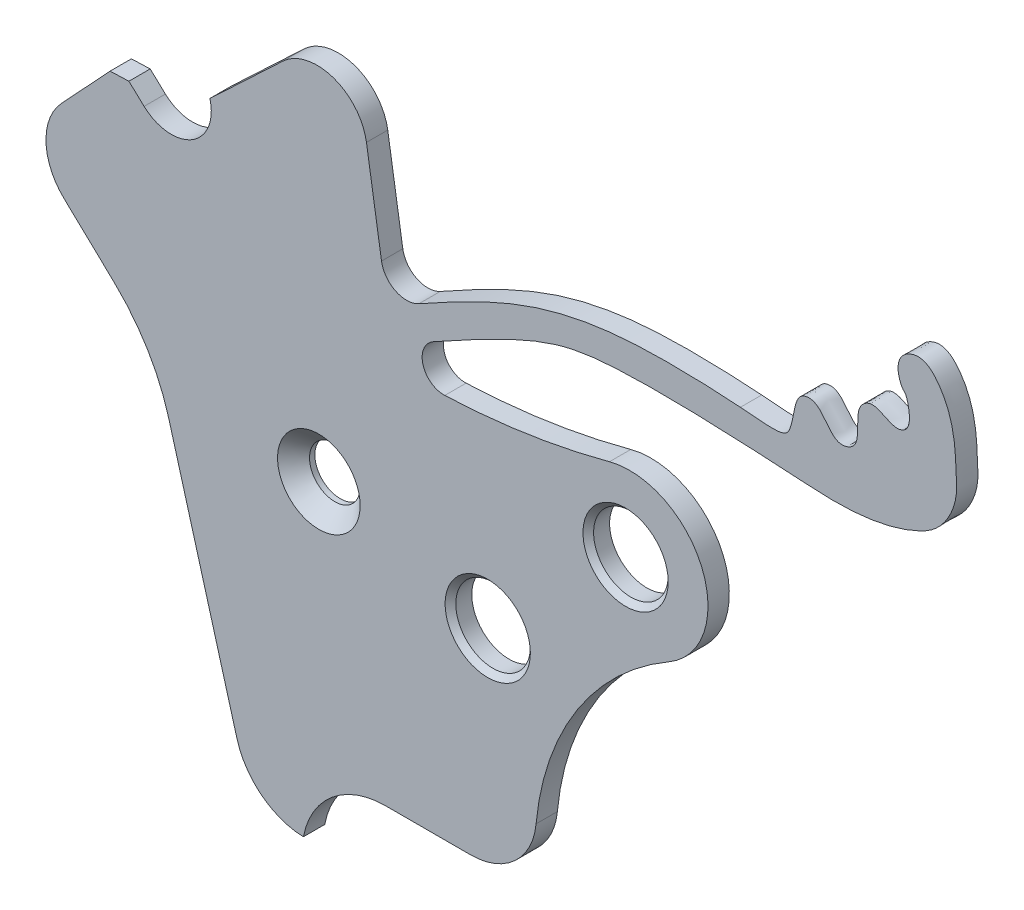
from build123d import *

# Parameters (mm, degrees)
BOSS_EXTRUDE1_DEPTH = 0.4
CUT_EXTRUDE1_REACH  = 2.4
SKETCH3_R           = 0.7
SKETCH3_R_2         = 0.475
CHAMFER1_SIZE       = 0.3
CHAMFER2_SIZE       = 0.1


with BuildPart() as part:
    # Sketch2 → Boss-Extrude1 (new body)
    with BuildSketch(Plane.XY):
        with BuildLine():
            Line((-3.280398103, 4.462745585), (-3.565990423, 4.728614807))
            Line((-3.565990423, 4.728614807), (-3.919317908, 4.715978))
            Line((-3.919317908, 4.715978), (-4.832992025, 3.734524376))
            ThreePointArc((-4.832992025, 3.734524376), (-5.12214982, 2.964294444), (-4.785260956, 2.213713154))
            Line((-4.785260956, 2.213713154), (-3.842676047, 1.320701474))
            ThreePointArc((-3.842676047, 1.320701474), (-3.215226534, 0.54105722), (-2.817993583, -0.377498188))
            Line((-2.817993583, -0.377498188), (-1.53754924, -4.943216753))
            ThreePointArc((-1.53754924, -4.943216753), (-1.073683574, -5.635355957), (-0.289950936, -5.918183091))
            ThreePointArc((-0.289950936, -5.918183091), (0.25193027, -5.00258665), (1.253002544, -4.642300121))
            Line((1.253002544, -4.642300121), (2.849087927, -4.642300121))
            ThreePointArc((2.849087927, -4.642300121), (3.679862266, -4.320845809), (4.077899324, -3.523923368))
            ThreePointArc((4.077899324, -3.523923368), (4.85231519, -1.28067152), (6.569808396, 0.357045144))
            ThreePointArc((6.569808396, 0.357045144), (7.194200096, 2.193242558), (5.455515812, 3.0525812))
            ThreePointArc((5.455515812, 3.0525812), (3.922850556, 2.733187243), (2.364301002, 2.58486809))
            ThreePointArc((2.364301002, 2.58486809), (1.954271819, 2.882940849), (2.148944892, 3.350993939))
            add(Edge.make_bspline(
                [(2.148944892, 3.350993939), (3.990784733, 4.377520224), (5.054570061, 4.749802783), (8.07736743, 4.610978963), (9.974761322, 4.487633157), (10.876148009, 4.612836581), (11.735902337, 5.082456398), (12.006850802, 5.630036331), (11.964613234, 6.088635426), (11.94790868, 6.582788519), (11.87304344, 7.169933604), (11.401729955, 7.698486926), (11.118368123, 7.641989696), (10.754115113, 7.433057717), (10.907458245, 7.045791734), (10.976067116, 6.975470818)],
                knots=[0, 0, 0, 0, 0.257493957, 0.509771918, 0.556127038, 0.67270813, 0.696759207, 0.766109929, 0.785364364, 0.796025603, 0.872722322, 0.911006436, 0.922367481, 0.931266838, 1, 1, 1, 1], degree=3))
            add(Edge.make_bspline(
                [(10.976067116, 6.975470818), (11.007230213, 6.943530086), (11.030998053, 6.927054365), (11.183543858, 6.436582216), (10.768131907, 6.210766166), (10.47441157, 6.546566685), (9.985825305, 6.237253123), (10.261407754, 5.63356727), (9.601064093, 5.416768823), (9.461950055, 5.99879585), (8.953943464, 5.941908396), (8.933009984, 5.615882839), (8.804013969, 5.099917733), (8.766496746, 5.091849472), (7.913807767, 5.167072227)],
                knots=[0, 0, 0, 0, 0.010451217, 0.122621216, 0.15375913, 0.268566734, 0.304390747, 0.463925269, 0.50835561, 0.652283215, 0.681879221, 0.784525671, 0.800049609, 1, 1, 1, 1], degree=3))
            add(Edge.make_bspline(
                [(7.913807767, 5.167072227), (7.613807084, 5.193537772), (4.779102247, 5.338097215), (3.361548013, 4.659831765), (1.879760763, 3.833976266)],
                knots=[0, 0, 0, 0, 0.29225871, 1, 1, 1, 1], degree=3))
            ThreePointArc((1.879760763, 3.833976266), (1.438926959, 3.821696872), (1.176473936, 4.176102906))
            Line((1.176473936, 4.176102906), (0.893773186, 5.964125991))
            ThreePointArc((0.893773186, 5.964125991), (0.27063154, 6.705053748), (-0.675545506, 6.500045332))
            Line((-0.675545506, 6.500045332), (-2.045683245, 5.208641086))
            ThreePointArc((-2.045683245, 5.208641086), (-2.381555089, 4.369737403), (-3.280398103, 4.462745585))
        make_face()
    extrude(amount=BOSS_EXTRUDE1_DEPTH)

    # Sketch3 → Cut-Extrude1 (cut, up to next)
    with BuildSketch(Plane.XY, mode=Mode.PRIVATE) as cut_extrude1_sk1:
        with Locations((3.171, -0.8)):
            Circle(SKETCH3_R)
    cut_extrude1_tool1 = extrude(cut_extrude1_sk1.sketch, amount=CUT_EXTRUDE1_REACH, mode=Mode.PRIVATE) & part.part
    add(cut_extrude1_tool1.solids().sort_by_distance((3.171, -0.8, 0))[0], mode=Mode.SUBTRACT)
    # Sketch3 → Cut-Extrude1 (cut, up to next)
    with BuildSketch(Plane.XY, mode=Mode.PRIVATE) as cut_extrude1_sk2:
        Circle(SKETCH3_R_2)
    cut_extrude1_tool2 = extrude(cut_extrude1_sk2.sketch, amount=CUT_EXTRUDE1_REACH, mode=Mode.PRIVATE) & part.part
    add(cut_extrude1_tool2.solids().sort_by_distance((0, 0, 0))[0], mode=Mode.SUBTRACT)
    # Sketch3 → Cut-Extrude1 (cut, up to next)
    with BuildSketch(Plane.XY, mode=Mode.PRIVATE) as cut_extrude1_sk3:
        with Locations((5.758559264, 1.652224614)):
            Circle(SKETCH3_R)
    cut_extrude1_tool3 = extrude(cut_extrude1_sk3.sketch, amount=CUT_EXTRUDE1_REACH, mode=Mode.PRIVATE) & part.part
    add(cut_extrude1_tool3.solids().sort_by_distance((5.758559, 1.652225, 0))[0], mode=Mode.SUBTRACT)

    # Chamfer1
    chamfer1_edges = [part.edges().sort_by_distance(p)[0] for p in [
        (-0.475, 0, 0.4),
    ]]
    chamfer(chamfer1_edges, length=CHAMFER1_SIZE)

    # Chamfer2
    chamfer2_edges = [part.edges().sort_by_distance(p)[0] for p in [
        (2.471, -0.8, 0.4),
        (5.058559264, 1.652224614, 0.4),
    ]]
    chamfer(chamfer2_edges, length=CHAMFER2_SIZE)


solid = part.part
